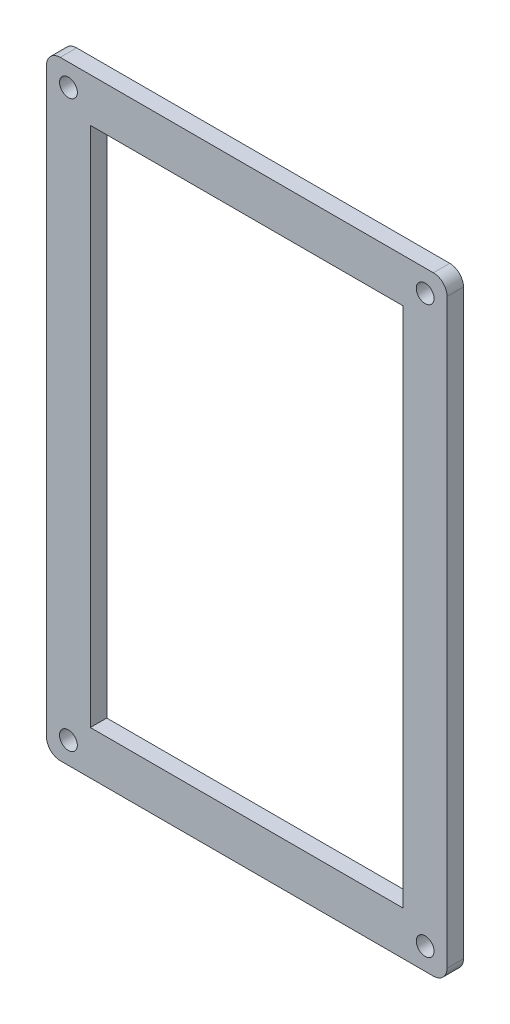
from build123d import *

# Parameters (mm, degrees)
MODEL_R         = 1.625
MODEL_W         = 57.1502154
MODEL_H         = 95.249807
EXTRUDE_1_DEPTH = 3


with BuildPart() as part:
    # Model → 凸台-拉伸1 (new body)
    with BuildSketch(Plane.XY):
        with BuildLine():
            Line((8.022847613, 111.260961872), (2.522847613, 111.260961872))
            ThreePointArc((2.522847613, 111.260961872), (0.75508066, 110.528728825), (0.022847613, 108.760961872))
            Line((0.022847613, 108.760961872), (0.022847613, 8.011154872))
            Line((0.022847613, 8.011154872), (0.022847613, 2.511154872))
            ThreePointArc((0.022847613, 2.511154872), (0.75508066, 0.743387919), (2.522847613, 0.011154872))
            Line((2.522847613, 0.011154872), (65.173063013, 0.011154872))
            Line((65.173063013, 0.011154872), (70.673063013, 0.011154872))
            ThreePointArc((70.673063013, 0.011154872), (72.440829966, 0.743387919), (73.173063013, 2.511154872))
            Line((73.173063013, 2.511154872), (73.173063013, 8.011154872))
            Line((73.173063013, 8.011154872), (73.173063013, 108.760961872))
            ThreePointArc((73.173063013, 108.760961872), (72.440829966, 110.528728825), (70.673063013, 111.260961872))
            Line((70.673063013, 111.260961872), (8.022847613, 111.260961872))
        make_face()
        with Locations((69.173063013, 4.011154872)):
            Circle(MODEL_R, mode=Mode.SUBTRACT)
        with Locations((4.022847613, 4.011154872)):
            Circle(MODEL_R, mode=Mode.SUBTRACT)
        with Locations((4.022847613, 107.260961872)):
            Circle(MODEL_R, mode=Mode.SUBTRACT)
        with Locations((69.173063013, 107.260961872)):
            Circle(MODEL_R, mode=Mode.SUBTRACT)
        with Locations((36.597955313, 55.636058372)):
            Rectangle(MODEL_W, MODEL_H, mode=Mode.SUBTRACT)
    extrude(amount=EXTRUDE_1_DEPTH)


solid = part.part
